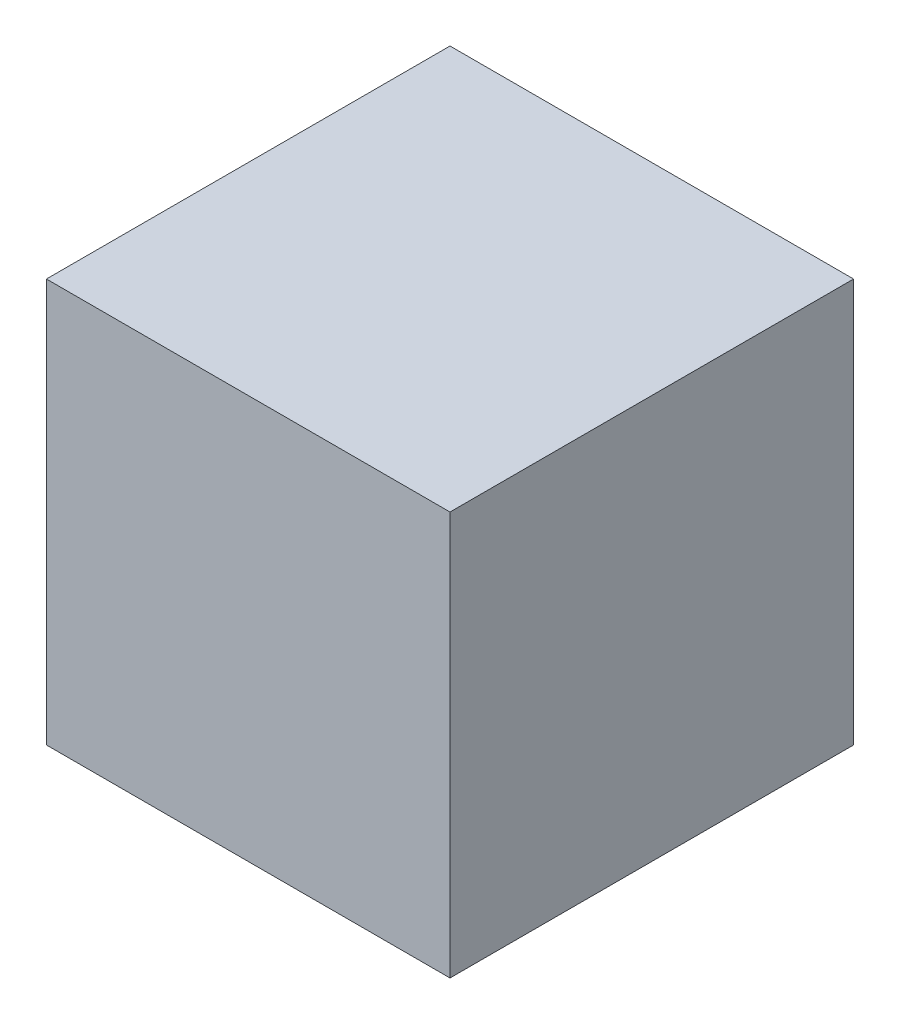
from build123d import *

# Parameters (mm, degrees)
SKETCH1_W           = 100
SKETCH1_H           = 100
BOSS_EXTRUDE1_DEPTH = 50


with BuildPart() as part:
    # Sketch1 → Boss-Extrude1 (new body, symmetric)
    with BuildSketch(Plane.XY):
        Rectangle(SKETCH1_W, SKETCH1_H)
    extrude(amount=BOSS_EXTRUDE1_DEPTH, both=True)


solid = part.part
